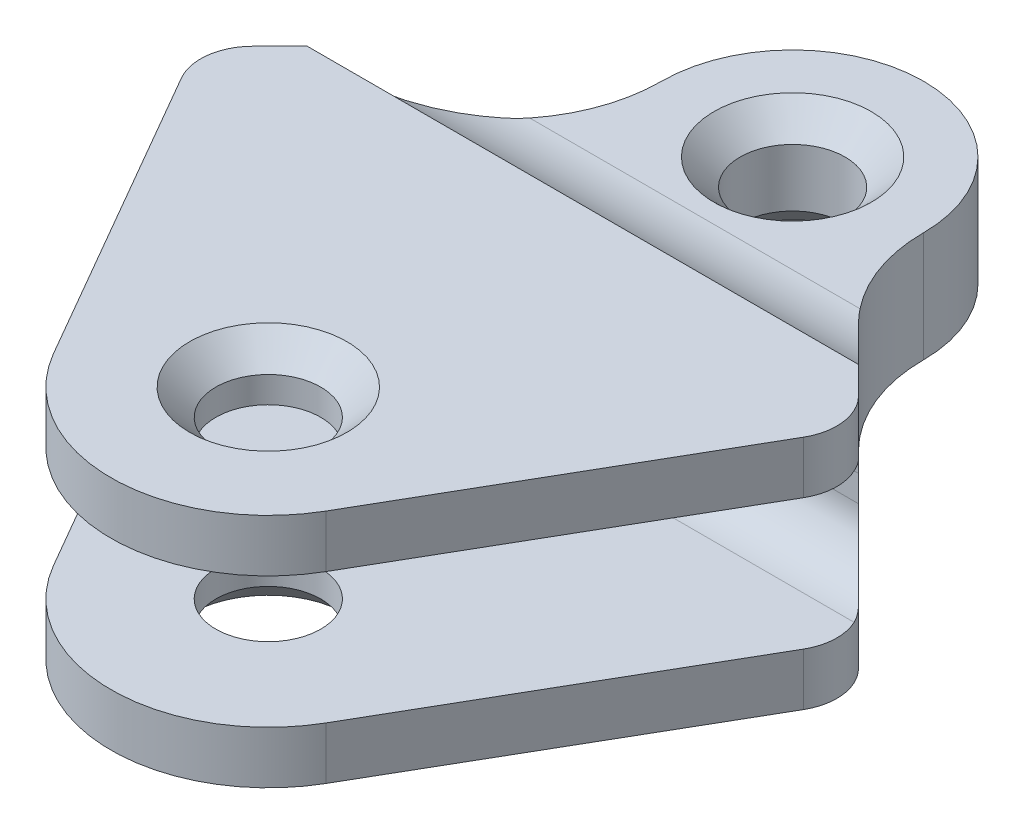
from build123d import *

# Parameters (mm, degrees)
SKETCH1_R               = 10
BOSS_EXTRUDE1_DEPTH     = 22.5
CUT_EXTRUDE1_DEPTH      = 61.66943013
CUT_EXTRUDE1_DEPTH_BACK = 61.66943013
CHAMFER1_SIZE           = 5


with BuildPart() as part:
    # Sketch1 → Boss-Extrude1 (new body, symmetric)
    with BuildSketch(Plane(origin=(0, 0, 0), x_dir=(1, 0, 0), z_dir=(0, 1, 0))):
        with BuildLine():
            Line((-25.980762114, -15), (-59.329684168, 42.762027375))
            ThreePointArc((-59.329684168, 42.762027375), (-60.583878744, 49.067289298), (-57.740497942, 54.833095187))
            Line((-57.740497942, 54.833095187), (-33.786796564, 78.786796564))
            ThreePointArc((-33.786796564, 78.786796564), (-27.283614025, 88.519497029), (-25, 100))
            ThreePointArc((-25, 100), (0, 125), (25, 100))
            ThreePointArc((25, 100), (27.283614025, 88.519497029), (33.786796564, 78.786796564))
            Line((33.786796564, 78.786796564), (57.740497942, 54.833095187))
            ThreePointArc((57.740497942, 54.833095187), (60.583878744, 49.067289298), (59.329684168, 42.762027375))
            Line((59.329684168, 42.762027375), (25.980762114, -15))
            ThreePointArc((25.980762114, -15), (0, -30), (-25.980762114, -15))
        make_face()
        with Locations((0, 100)):
            Circle(SKETCH1_R, mode=Mode.SUBTRACT)
        Circle(SKETCH1_R, mode=Mode.SUBTRACT)
    extrude(amount=BOSS_EXTRUDE1_DEPTH, both=True)

    # Sketch2 → Cut-Extrude1 (cut, two sides)
    with BuildSketch(Plane(origin=(0, 0, 0), x_dir=(0, 0, -1), z_dir=(1, 0, 0))) as cut_extrude1_sk:
        with BuildLine():
            Line((-30, 12.5), (52, 12.5))
            ThreePointArc((52, 12.5), (59.071067812, 9.571067812), (62, 2.5))
            Line((62, 2.5), (62, -2.5))
            ThreePointArc((62, -2.5), (59.071067812, -9.571067812), (52, -12.5))
            Line((52, -12.5), (-30, -12.5))
            Line((-30, -12.5), (-30, 12.5))
        make_face()
        with BuildLine():
            Line((81.354156504, 10.5), (125, 10.5))
            Line((125, 10.5), (125, 22.5))
            Line((125, 22.5), (78.786796564, 22.5))
            Line((78.786796564, 22.5), (60, 22.5))
            ThreePointArc((60, 22.5), (69.10670779, 13.705505282), (81.354156504, 10.5))
        make_face()
        with BuildLine():
            Line((125, -22.5), (125, -10.5))
            Line((125, -10.5), (81.354156504, -10.5))
            ThreePointArc((81.354156504, -10.5), (69.10670779, -13.705505282), (60, -22.5))
            Line((60, -22.5), (78.786796564, -22.5))
            Line((78.786796564, -22.5), (125, -22.5))
        make_face()
    extrude(amount=CUT_EXTRUDE1_DEPTH, mode=Mode.SUBTRACT)
    extrude(cut_extrude1_sk.sketch, amount=-CUT_EXTRUDE1_DEPTH_BACK, mode=Mode.SUBTRACT)

    # Chamfer1
    chamfer1_edges = [part.edges().sort_by_distance(p)[0] for p in [
        (-10, -22.5, 0),
        (-10, 22.5, 0),
        (-10, -10.5, -100),
        (-10, 10.5, -100),
    ]]
    chamfer(chamfer1_edges, length=CHAMFER1_SIZE)


solid = part.part
